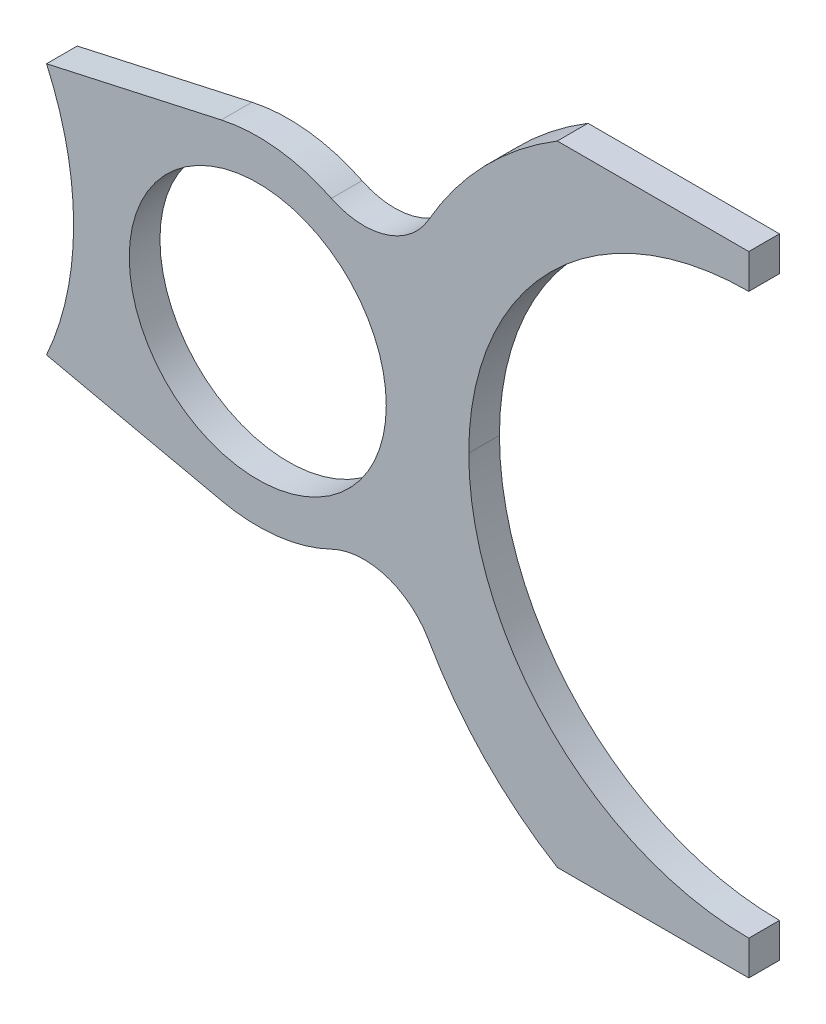
from build123d import *

# Parameters (mm, degrees)
MODEL_R             = 8.375
BOSS_EXTRUDE1_DEPTH = 2


with BuildPart() as part:
    # Model → Boss-Extrude1 (new body)
    with BuildSketch(Plane.XY):
        with BuildLine():
            Line((74.448010934, 2.249927661), (74.448004895, 4.500084718))
            Line((74.448004895, 4.500084718), (61.968150916, 4.500005388))
            ThreePointArc((61.968150916, 4.500005388), (57.22880439, 0.718152869), (53.588491837, -4.130758193))
            ThreePointArc((53.588491837, -4.130758193), (50.805713706, -6.36868051), (47.244750466, -6.10092834))
            ThreePointArc((47.244750466, -6.10092834), (43.728043409, -5.074712325), (40.069365021, -5.260239392))
            Line((40.069365021, -5.260239392), (28.682107763, -7.782293479))
            ThreePointArc((28.682107763, -7.782293479), (30.001771143, -11.797316195), (30.448277219, -16.000000001))
            ThreePointArc((30.448277219, -16.000000001), (30.001771143, -20.202683806), (28.682107763, -24.217706522))
            Line((28.682107763, -24.217706522), (40.069365021, -26.73976061))
            ThreePointArc((40.069365021, -26.73976061), (43.728043409, -26.925287677), (47.244750466, -25.899071661))
            ThreePointArc((47.244750466, -25.899071661), (50.805713706, -25.631319491), (53.588491837, -27.869241808))
            ThreePointArc((53.588491837, -27.869241808), (57.22880439, -32.718152871), (61.968150916, -36.500005389))
            Line((61.968150916, -36.500005389), (74.448004895, -36.500084719))
            Line((74.448004895, -36.500084719), (74.448010934, -34.249927662))
            ThreePointArc((74.448010934, -34.249927662), (61.543360309, -28.904678271), (56.198007214, -16.000070602))
            ThreePointArc((56.198007214, -16.000070602), (61.543310386, -3.095371653), (74.448010934, 2.249927661))
        make_face()
        with Locations((42.448007213, -15.999981536)):
            Circle(MODEL_R, mode=Mode.SUBTRACT)
    extrude(amount=BOSS_EXTRUDE1_DEPTH)


solid = part.part
